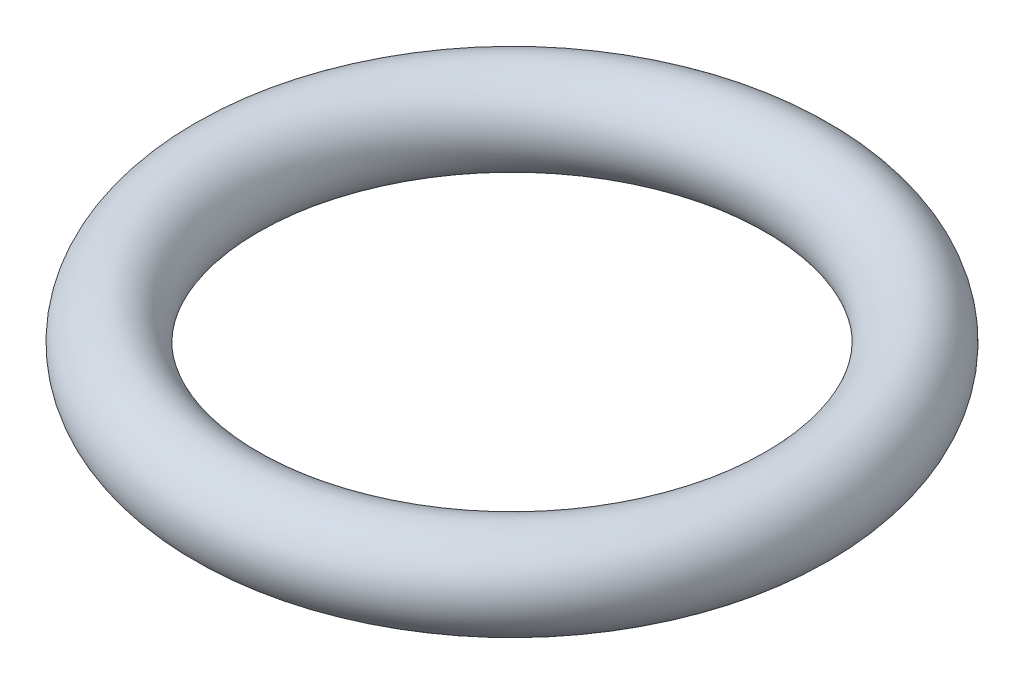
from build123d import *

# Parameters (mm, degrees)
SKETCH1_R = 1.25


with BuildPart() as part:
    # Sketch1 → Revolve1 (revolve)
    with BuildSketch(Plane.XY):
        with Locations((-8, 0)):
            Circle(SKETCH1_R)
    revolve(axis=Axis((0, -2.443181818, 0), (0, 1, 0)))


solid = part.part
